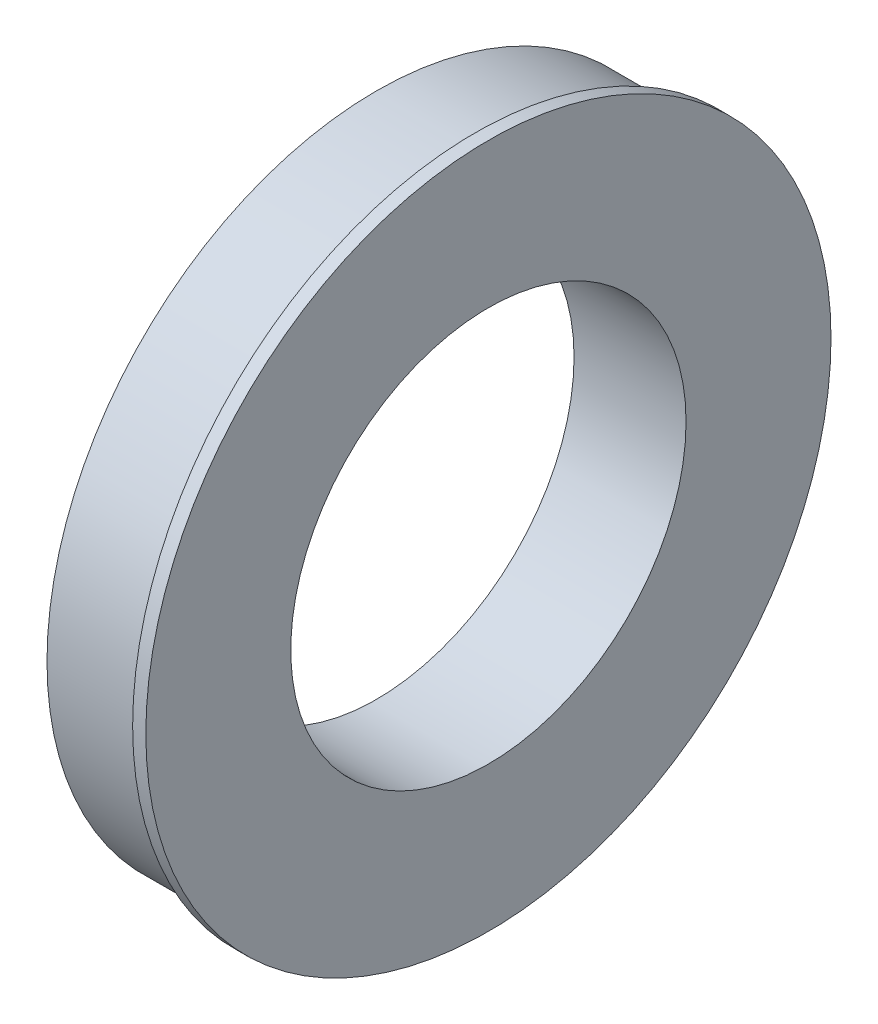
from build123d import *

# Parameters (mm, degrees)
ESQUISSE1_R        = 63.5
ESQUISSE1_R_2      = 38.1
BOSS_EXTRU_1_DEPTH = 9.525
ESQUISSE2_R        = 66.04
ESQUISSE2_R_2      = 38.1
BOSS_EXTRU_2_DEPTH = 2.54


with BuildPart() as part:
    # Esquisse1 → Boss.-Extru.1 (new body, symmetric)
    with BuildSketch(Plane(origin=(0, 0, 0), x_dir=(0, 0, -1), z_dir=(1, 0, 0))):
        Circle(ESQUISSE1_R)
        Circle(ESQUISSE1_R_2, mode=Mode.SUBTRACT)
    extrude(amount=BOSS_EXTRU_1_DEPTH, both=True)

    # Esquisse2 → Boss.-Extru.2 (add)
    with BuildSketch(Plane(origin=(9.525, 0, 0), x_dir=(0, 0, -1), z_dir=(1, 0, 0))):
        Circle(ESQUISSE2_R)
        Circle(ESQUISSE2_R_2, mode=Mode.SUBTRACT)
    extrude(amount=BOSS_EXTRU_2_DEPTH)


solid = part.part
